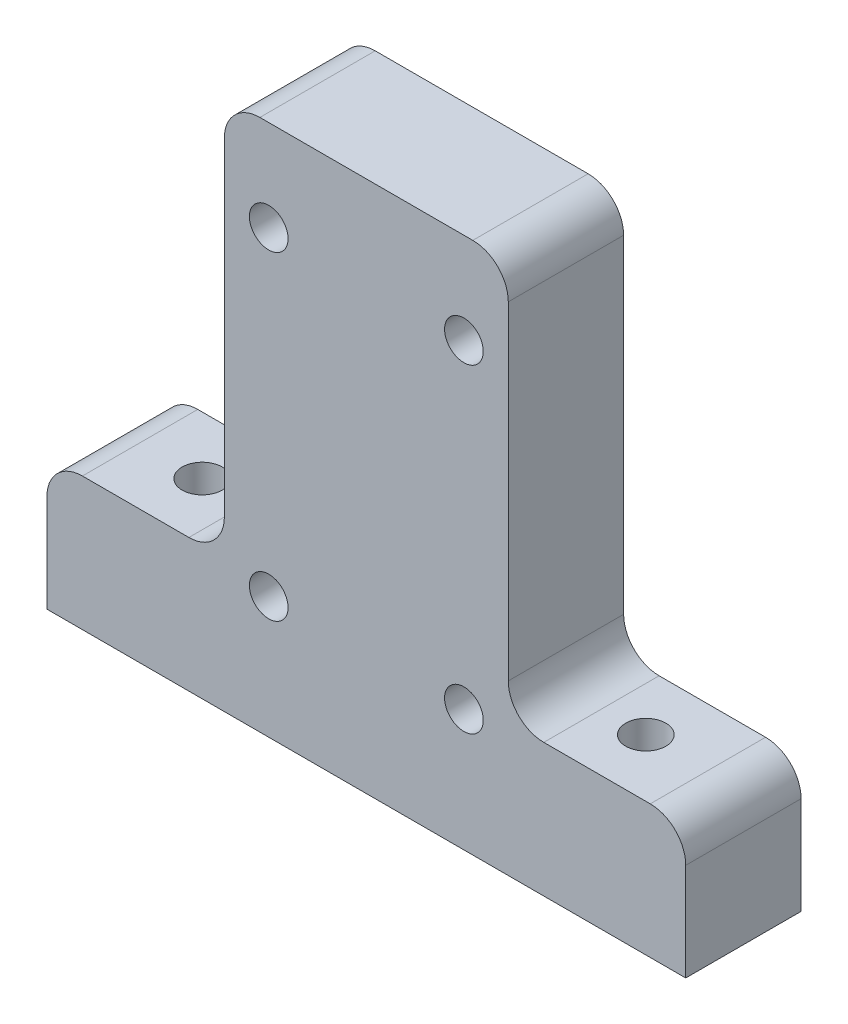
from build123d import *

# Parameters (mm, degrees)
SKETCH1_W           = 16
SKETCH1_H           = 30
BOSS_EXTRUDE1_DEPTH = 6.5
SKETCH3_R           = 1.09
CUT_EXTRUDE1_DEPTH  = 7.5
FILLET1_R           = 2
SKETCH5_W           = 10
SKETCH5_H           = 7.5
BOSS_EXTRUDE2_DEPTH = 6.5
FILLET2_R           = 2
FILLET3_R           = 2
FILLET4_R           = 2
SKETCH4_R           = 1.13
CUT_EXTRUDE2_DEPTH  = 31


with BuildPart() as part:
    # Sketch1 → Boss-Extrude1 (new body)
    with BuildSketch(Plane.XY):
        with Locations((8, 15)):
            Rectangle(SKETCH1_W, SKETCH1_H)
    extrude(amount=BOSS_EXTRUDE1_DEPTH)

    # Sketch3 → Cut-Extrude1 (cut, through all)
    with BuildSketch(Plane(origin=(0, 0, 0), x_dir=(-1, 0, 0), z_dir=(0, 0, -1))):
        with Locations((-13.5, 6.87)):
            Circle(SKETCH3_R)
        with Locations((-2.5, 6.87)):
            Circle(SKETCH3_R)
        with Locations((-2.5, 24.87)):
            Circle(SKETCH3_R)
        with Locations((-13.5, 24.87)):
            Circle(SKETCH3_R)
    extrude(amount=-CUT_EXTRUDE1_DEPTH, mode=Mode.SUBTRACT)

    # Fillet1
    fillet1_edges = [part.edges().sort_by_distance(p)[0] for p in [
        (0, 30, 3.25),
        (16, 30, 3.25),
    ]]
    fillet(fillet1_edges, radius=FILLET1_R)

    # Sketch5 → Boss-Extrude2 (add)
    with BuildSketch(Plane.XY.offset(6.5)):
        with Locations((-5, 3.75)):
            Rectangle(SKETCH5_W, SKETCH5_H)
        with Locations((21, 3.75)):
            Rectangle(SKETCH5_W, SKETCH5_H)
    extrude(amount=-BOSS_EXTRUDE2_DEPTH)

    # Fillet2
    fillet2_edges = [part.edges().sort_by_distance(p)[0] for p in [
        (0, 7.5, 3.25),
        (16, 7.5, 3.25),
    ]]
    fillet(fillet2_edges, radius=FILLET2_R)

    # Fillet3
    fillet3_edges = [part.edges().sort_by_distance(p)[0] for p in [
        (26, 7.5, 3.25),
    ]]
    fillet(fillet3_edges, radius=FILLET3_R)

    # Fillet4
    fillet4_edges = [part.edges().sort_by_distance(p)[0] for p in [
        (-10, 7.5, 3.25),
    ]]
    fillet(fillet4_edges, radius=FILLET4_R)

    # Sketch4 → Cut-Extrude2 (cut, through all)
    with BuildSketch(Plane.XZ):
        with Locations((20.5, 3.25)):
            Circle(SKETCH4_R)
        with Locations((-4.5, 3.25)):
            Circle(SKETCH4_R)
    extrude(amount=-CUT_EXTRUDE2_DEPTH, mode=Mode.SUBTRACT)


solid = part.part
